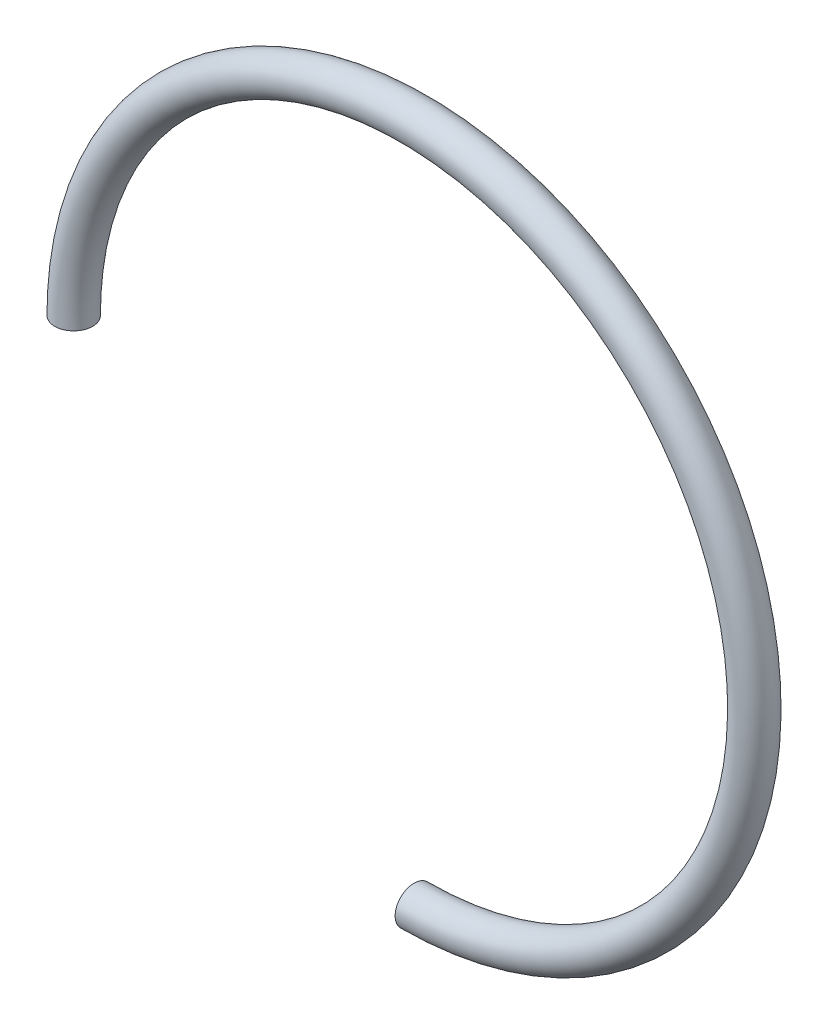
from build123d import *

# Parameters (mm, degrees)
VARREDURA1_PROFILE_R = 0.25


with BuildPart() as part:
    # Varredura1: sweep along a path in Esboço1
    with BuildLine(Plane.XY) as varredura1_path:
        ThreePointArc((0, -4.5), (3.181980515, 3.181980515), (-4.5, 0))
    # Varredura1 profile (on start of the path) → Varredura1 (sweep)
    with BuildSketch(Plane(origin=(0, -4.5, 0), x_dir=(0, 1, 0), z_dir=(1, 0, 0))):
        Circle(VARREDURA1_PROFILE_R)
    sweep(path=varredura1_path.line)


solid = part.part
